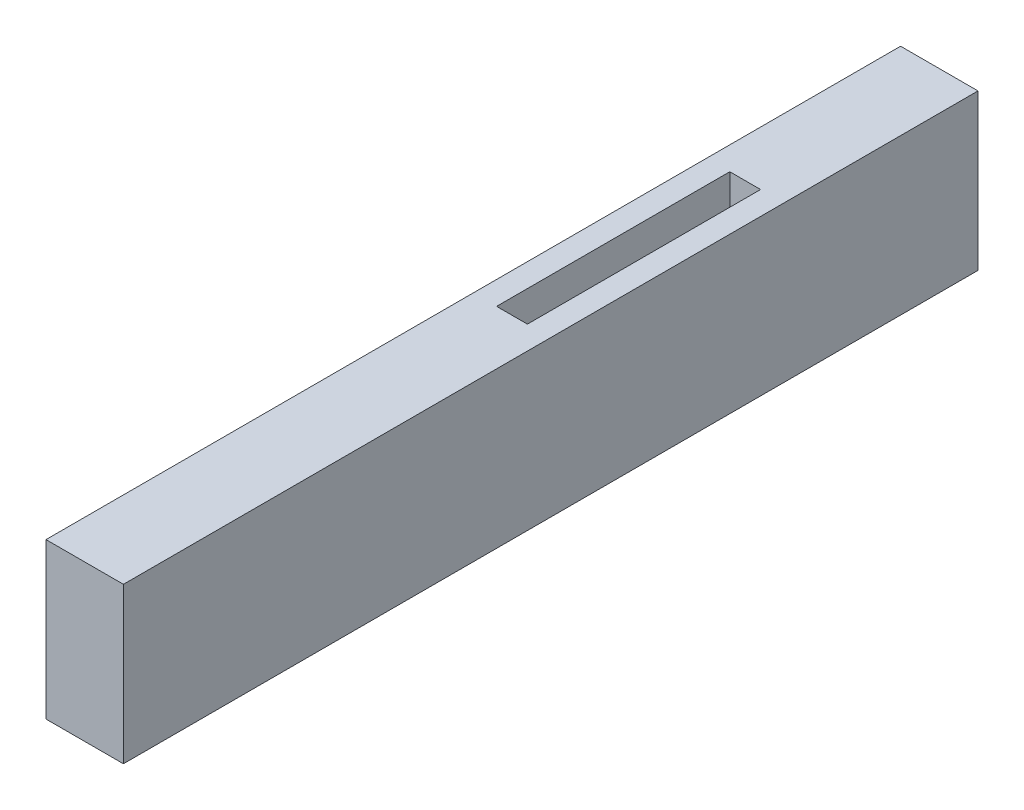
from build123d import *

# Parameters (mm, degrees)
SKETCH1_W           = 4.980670257
SKETCH1_H           = 54.9718421
BOSS_EXTRUDE1_DEPTH = 10
SKETCH2_W           = 1.980670257
SKETCH2_H           = 15
CUT_EXTRUDE2_DEPTH  = 7
SKETCH4_W           = 1.980670257
SKETCH4_H           = 25.98592105
CUT_EXTRUDE3_DEPTH  = 7


with BuildPart() as part:
    # Sketch1 → Boss-Extrude1 (new body)
    with BuildSketch(Plane(origin=(0, 0, 0), x_dir=(1, 0, 0), z_dir=(0, 1, 0))):
        with Locations((-11.806033203, 3.043742935)):
            Rectangle(SKETCH1_W, SKETCH1_H)
    extrude(amount=BOSS_EXTRUDE1_DEPTH)

    # Sketch2 → Cut-Extrude2 (cut)
    with BuildSketch(Plane(origin=(0, 10, 0), x_dir=(1, 0, 0), z_dir=(0, 1, 0))):
        with Locations((-11.806033203, 10.543742935)):
            Rectangle(SKETCH2_W, SKETCH2_H)
    extrude(amount=-CUT_EXTRUDE2_DEPTH, mode=Mode.SUBTRACT)

    # Sketch4 → Cut-Extrude3 (cut)
    with BuildSketch(Plane.XZ):
        with Locations((-11.806033203, 9.94921759)):
            Rectangle(SKETCH4_W, SKETCH4_H)
    extrude(amount=-CUT_EXTRUDE3_DEPTH, mode=Mode.SUBTRACT)


solid = part.part
